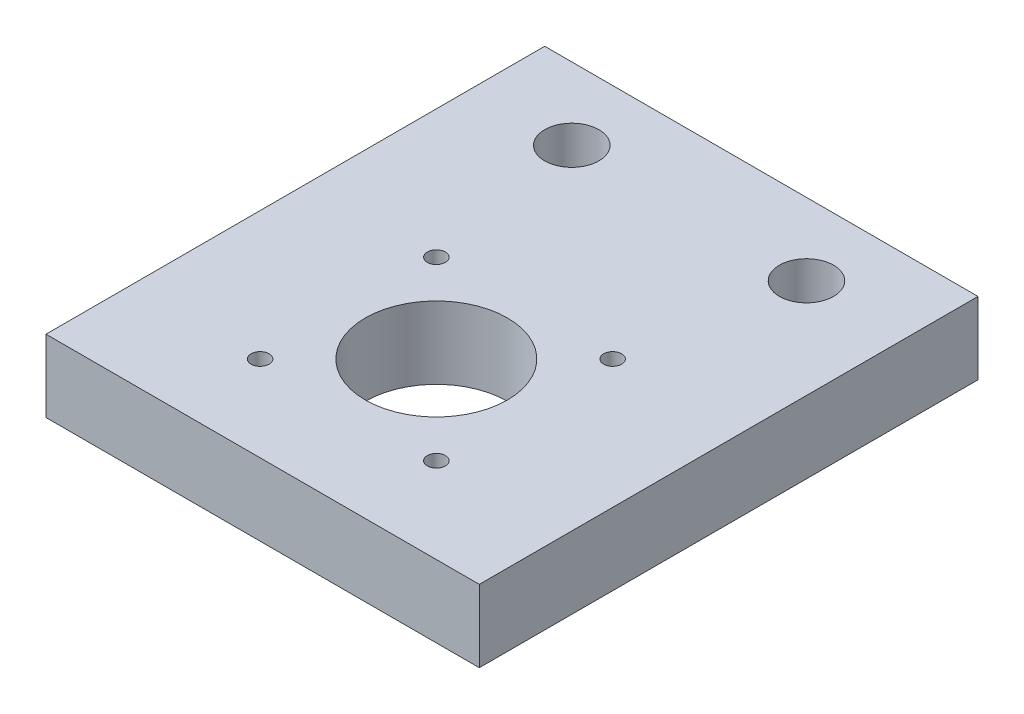
from build123d import *

# Parameters (mm, degrees)
SKETCH1_W           = 76.2
SKETCH1_H           = 87.7
SKETCH1_R           = 4.7625
BOSS_EXTRUDE1_DEPTH = 12.7
SKETCH2_R           = 12.5
SKETCH2_R_2         = 1.5875
CUT_EXTRUDE1_DEPTH  = 12.7


with BuildPart() as part:
    # Sketch1 → Boss-Extrude1 (new body)
    with BuildSketch(Plane(origin=(0, 0, 0), x_dir=(1, 0, 0), z_dir=(0, 1, 0))):
        with Locations((20.6375, -31.15)):
            Rectangle(SKETCH1_W, SKETCH1_H)
        Circle(SKETCH1_R, mode=Mode.SUBTRACT)
        with Locations((41.275, 0)):
            Circle(SKETCH1_R, mode=Mode.SUBTRACT)
    extrude(amount=BOSS_EXTRUDE1_DEPTH)

    # Sketch2 → Cut-Extrude1 (cut)
    with BuildSketch(Plane(origin=(0, 12.7, 0), x_dir=(1, 0, 0), z_dir=(0, 1, 0))):
        with Locations((20.6375, -44.45)):
            Circle(SKETCH2_R)
        with Locations((36.1375, -28.95)):
            Circle(SKETCH2_R_2)
        with Locations((5.1375, -28.95)):
            Circle(SKETCH2_R_2)
        with Locations((36.1375, -59.95)):
            Circle(SKETCH2_R_2)
        with Locations((5.1375, -59.95)):
            Circle(SKETCH2_R_2)
    extrude(amount=-CUT_EXTRUDE1_DEPTH, mode=Mode.SUBTRACT)


solid = part.part
